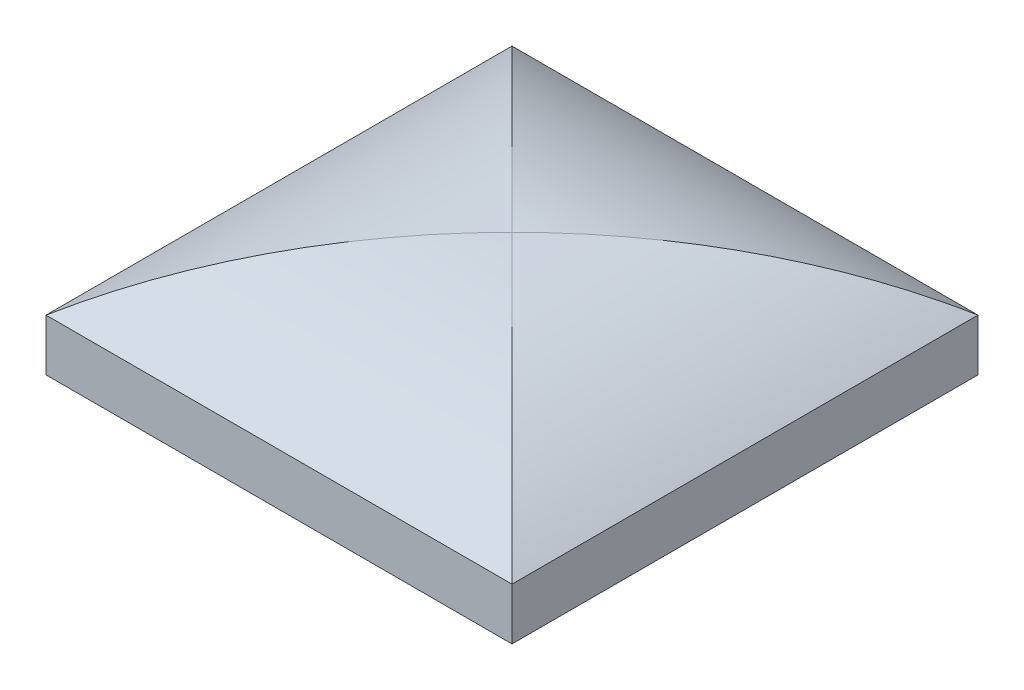
from build123d import *

# Parameters (mm, degrees)
BOSS_EXTRUDE6_DEPTH = 45
BOSS_EXTRUDE8_DEPTH = 45


with BuildPart() as part:
    # Sketch4 → Boss-Extrude6 (new, symmetric)
    with BuildSketch(Plane.XY):
        with BuildLine():
            Line((-45, 0), (45, 0))
            Line((45, 0), (45, 10))
            ThreePointArc((45, 10), (0, 23.856217223), (-45, 10))
            Line((-45, 10), (-45, 0))
        make_face()
    extrude(amount=BOSS_EXTRUDE6_DEPTH, both=True)


with BuildPart() as body_2:
    # Sketch9 → Boss-Extrude8 (new, symmetric)
    with BuildSketch(Plane(origin=(0, 0, 0), x_dir=(0, 0, -1), z_dir=(1, 0, 0))):
        with BuildLine():
            Line((-45, 0), (45, 0))
            Line((45, 0), (45, 10))
            ThreePointArc((45, 10), (0, 23.856217223), (-45, 10))
            Line((-45, 10), (-45, 0))
        make_face()
    extrude(amount=BOSS_EXTRUDE8_DEPTH, both=True)


with BuildPart() as part_1:
    add(part.part)

    # Combine1: intersect body 2
    add(body_2.part, mode=Mode.INTERSECT)


solid = part_1.part
